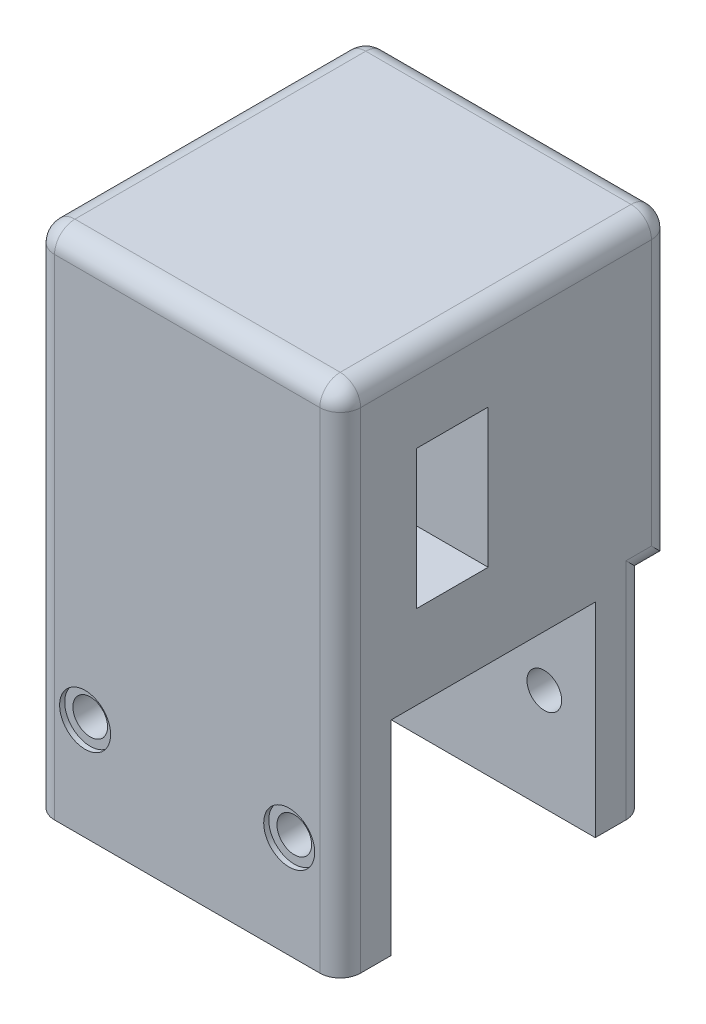
from build123d import *

# Parameters (mm, degrees)
SKETCH1_W               = 30
SKETCH1_H               = 50
BOSS_EXTRUDE1_DEPTH     = 15
SKETCH6_W               = 30
SKETCH6_H               = 30
BOSS_EXTRUDE2_DEPTH     = 2.5
SKETCH2_W               = 30
SKETCH2_H               = 20
CUT_EXTRUDE1_DEPTH      = 20
CUT_EXTRUDE2_DEPTH      = 41.078048855
CUT_EXTRUDE2_DEPTH_BACK = 41.078048855
SKETCH3_R               = 1.7
SKETCH5_W               = 7
SKETCH5_H               = 13.6
CUT_EXTRUDE5_DEPTH      = 22.8
CUT_EXTRUDE8_START      = -4.5
SKETCH3_4_R             = 2.5
CUT_EXTRUDE8_DEPTH      = 0.5
MIRROR4_START           = -4.5
MIRROR4_COPY_1_SKETCH_R = 2.5
MIRROR4_COPY_1_DEPTH    = 0.5
MIRROR4_COPY_2_SKETCH_R = 2.5
MIRROR4_COPY_2_DEPTH    = 0.5
FILLET1_R               = 2
SKETCH7_R               = 12
CUT_EXTRUDE9_DEPTH      = 12
CUT_EXTRUDE10_REACH     = 45.661
SKETCH7_4_R             = 4.5


with BuildPart() as part:
    # Sketch1 → Boss-Extrude1 (new, symmetric)
    with BuildSketch(Plane.XY):
        Rectangle(SKETCH1_W, SKETCH1_H)
    extrude(amount=BOSS_EXTRUDE1_DEPTH, both=True)

    # Sketch6 → Boss-Extrude2 (add)
    with BuildSketch(Plane(origin=(0, 0, -15), x_dir=(-1, 0, 0), z_dir=(0, 0, -1))):
        with Locations((0, 10)):
            Rectangle(SKETCH6_W, SKETCH6_H)
    extrude(amount=BOSS_EXTRUDE2_DEPTH)

    # Sketch2 → Cut-Extrude1 (cut)
    with BuildSketch(Plane.XZ.offset(25)):
        Rectangle(SKETCH2_W, SKETCH2_H)
    extrude(amount=-CUT_EXTRUDE1_DEPTH, mode=Mode.SUBTRACT)

    # Sketch3 → Cut-Extrude2 (cut, two sides: drawn at the far end of the back side and taken through both)
    with BuildSketch(Plane(origin=(0, 0, 10), x_dir=(-1, 0, 0), z_dir=(0, 0, -1)).offset(-CUT_EXTRUDE2_DEPTH_BACK)):
        with Locations((-10, -15)):
            Circle(SKETCH3_R)
        with Locations((10, -15)):
            Circle(SKETCH3_R)
    extrude(amount=CUT_EXTRUDE2_DEPTH + CUT_EXTRUDE2_DEPTH_BACK, mode=Mode.SUBTRACT)

    # Sketch5 → Cut-Extrude5 (cut)
    with BuildSketch(Plane(origin=(15, 0, 0), x_dir=(0, 0, -1), z_dir=(1, 0, 0))):
        with Locations((-4, 10)):
            Rectangle(SKETCH5_W, SKETCH5_H)
    extrude(amount=-CUT_EXTRUDE5_DEPTH, mode=Mode.SUBTRACT)

    # Sketch3_4 → Cut-Extrude8 (cut)
    with BuildSketch(Plane(origin=(0, 0, 10), x_dir=(-1, 0, 0), z_dir=(0, 0, -1)).offset(CUT_EXTRUDE8_START)):
        with Locations((-10, -15)):
            Circle(SKETCH3_4_R)
    cut_extrude8 = extrude(amount=-CUT_EXTRUDE8_DEPTH, mode=Mode.SUBTRACT)

    # Mirror3: Cut-Extrude8 across plane
    add(cut_extrude8.mirror(Plane(origin=(0, 0, 0), x_dir=(0, 0, 1), z_dir=(1, 0, 0))), mode=Mode.SUBTRACT)

    # Mirror4 copy 1 sketch → Mirror4 copy 1 (cut)
    with BuildSketch(Plane.XY.offset(-10).offset(MIRROR4_START)):
        with Locations((-10, -15)):
            Circle(MIRROR4_COPY_1_SKETCH_R)
    extrude(amount=-MIRROR4_COPY_1_DEPTH, mode=Mode.SUBTRACT)

    # Mirror4 copy 2 sketch → Mirror4 copy 2 (cut)
    with BuildSketch(Plane(origin=(0, 0, -10), x_dir=(-1, 0, 0), z_dir=(0, 0, 1)).offset(MIRROR4_START)):
        with Locations((-10, 15)):
            Circle(MIRROR4_COPY_2_SKETCH_R)
    extrude(amount=-MIRROR4_COPY_2_DEPTH, mode=Mode.SUBTRACT)

    # Fillet1
    fillet1_edges = [part.edges().sort_by_distance(p)[0] for p in [
        (0, 25, 15),
        (-15, 25, -1.25),
        (0, 25, -17.5),
        (15, 25, -1.25),
        (-15, -15, -15),
        (-15, -5, -16.25),
        (-15, 10, -17.5),
        (15, 10, -17.5),
        (15, -5, -16.25),
        (15, -15, -15),
        (-15, 0, 15),
        (15, 0, 15),
    ]]
    fillet(fillet1_edges, radius=FILLET1_R)

    # Sketch7 → Cut-Extrude9 (cut)
    with BuildSketch(Plane(origin=(0, 0, -17.5), x_dir=(-1, 0, 0), z_dir=(0, 0, -1))):
        with Locations((0, 10)):
            Circle(SKETCH7_R)
    extrude(amount=-CUT_EXTRUDE9_DEPTH, mode=Mode.SUBTRACT)

    # Sketch7_4 → Cut-Extrude10 (cut, up to next)
    with BuildSketch(Plane(origin=(0, 0, -17.5), x_dir=(-1, 0, 0), z_dir=(0, 0, -1)), mode=Mode.PRIVATE) as cut_extrude10_sk1:
        with Locations((0, 10)):
            Circle(SKETCH7_4_R)
    cut_extrude10_tool1 = extrude(cut_extrude10_sk1.sketch, amount=-CUT_EXTRUDE10_REACH, mode=Mode.PRIVATE) & part.part
    add(cut_extrude10_tool1.solids().sort_by_distance((0, 10, -17.5))[0], mode=Mode.SUBTRACT)


solid = part.part
